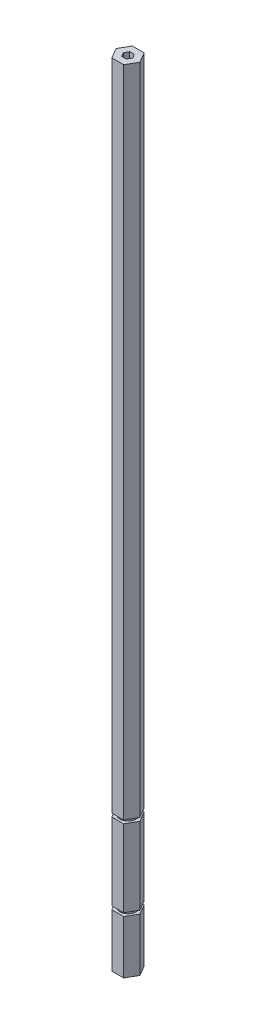
from build123d import *

# Parameters (mm, degrees)
BOSS_EXTRUDE1_DEPTH = 488.95
SKETCH3_W           = 2.54
SKETCH3_H           = 2.032


with BuildPart() as part:
    # Sketch1 → Boss-Extrude1 (new body)
    with BuildSketch(Plane(origin=(0, 0, 0), x_dir=(1, 0, 0), z_dir=(0, 1, 0))):
        Polygon((7.332348419, 0), (3.666174209, 6.35), (-3.666174209, 6.35), (-7.332348419, 0), (-3.666174209, -6.35), (3.666174209, -6.35), align=None)
        Polygon((1.443375673, 2.5), (-1.443375673, 2.5), (-2.886751346, 0), (-1.443375673, -2.5), (1.443375673, -2.5), (2.886751346, 0), align=None, mode=Mode.SUBTRACT)
    extrude(amount=BOSS_EXTRUDE1_DEPTH)

    # Sketch3 → Cut-Revolve2 (revolve, cut)
    with BuildSketch(Plane(origin=(0, 0, 0), x_dir=(0, 0, -1), z_dir=(1, 0, 0))):
        with Locations((6.2865, 83.566)):
            Rectangle(SKETCH3_W, SKETCH3_H)
        with Locations((6.2865, 33.909)):
            Rectangle(SKETCH3_W, SKETCH3_H)
    revolve(axis=Axis((0, 488.95, 0), (0, -1, 0)), mode=Mode.SUBTRACT)


solid = part.part
